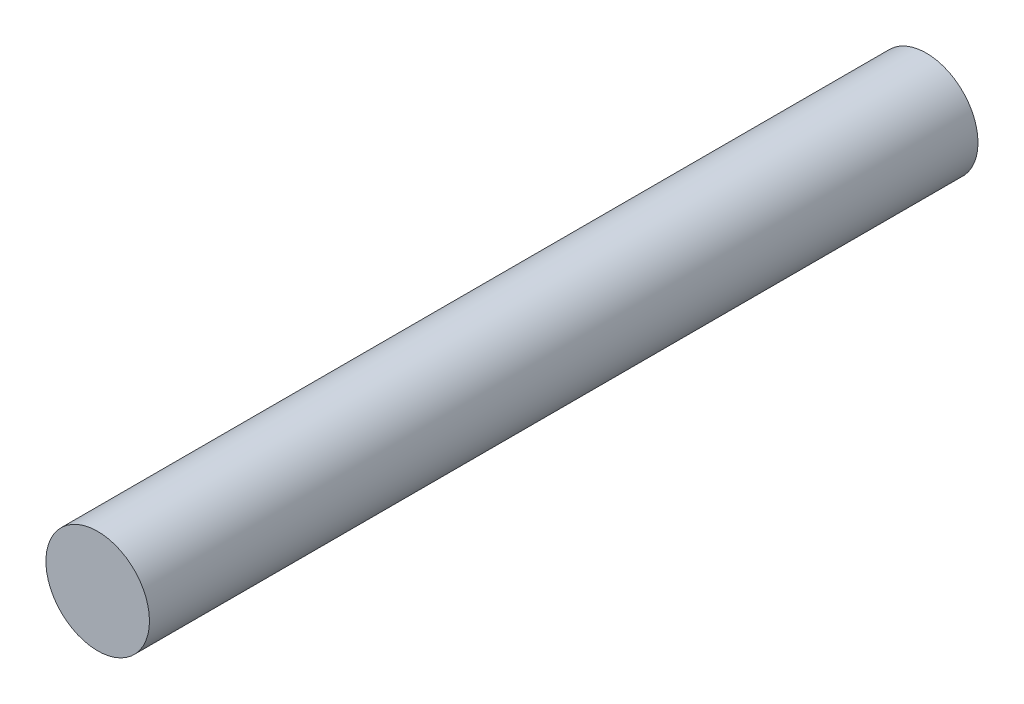
from build123d import *

# Parameters (mm, degrees)
SKETCH1_R           = 3.175
BOSS_EXTRUDE1_DEPTH = 50.8


with BuildPart() as part:
    # Sketch1 → Boss-Extrude1 (new body)
    with BuildSketch(Plane.XY):
        Circle(SKETCH1_R)
    extrude(amount=BOSS_EXTRUDE1_DEPTH)


solid = part.part
